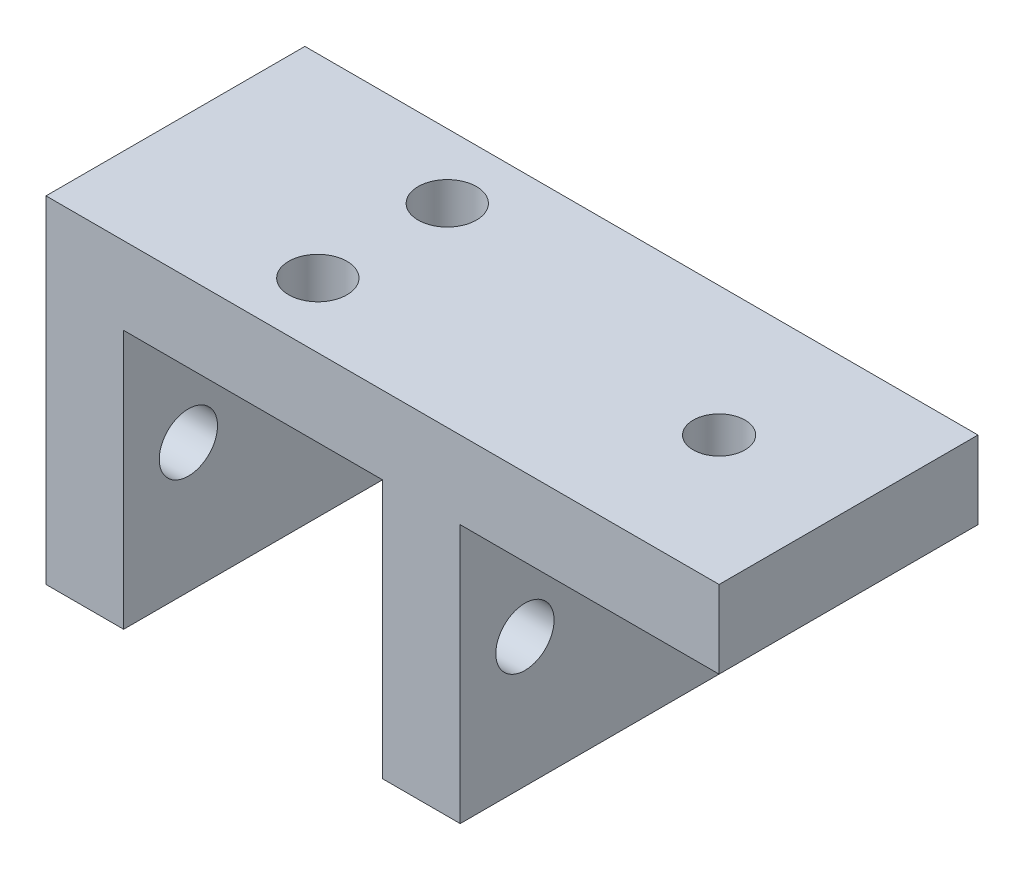
from build123d import *

# Parameters (mm, degrees)
BOSS_EXTRUDE3_DEPTH     = 20
SKETCH9_R               = 2.25
CUT_EXTRUDE1_DEPTH      = 47
CUT_EXTRUDE1_DEPTH_BACK = 7
SKETCH10_R              = 2.25
CUT_EXTRUDE2_DEPTH      = 21
CUT_EXTRUDE2_DEPTH_BACK = 7
SKETCH11_R              = 2
CUT_EXTRUDE3_DEPTH      = 21
CUT_EXTRUDE3_DEPTH_BACK = 7


with BuildPart() as part:
    # Sketch7 → Boss-Extrude3 (new body)
    with BuildSketch(Plane.XY):
        Polygon((-52, -26), (-52, 0), (0, 0), (0, -6), (-20, -6), (-20, -26), (-26, -26), (-26, -6), (-46, -6), (-46, -26), align=None)
    extrude(amount=BOSS_EXTRUDE3_DEPTH)

    # Sketch9 → Cut-Extrude1 (cut, two sides)
    with BuildSketch(Plane(origin=(-46, 0, 0), x_dir=(0, 0, -1), z_dir=(1, 0, 0))) as cut_extrude1_sk:
        with Locations((-15, -16)):
            Circle(SKETCH9_R)
        with Locations((-5, -16)):
            Circle(SKETCH9_R)
    extrude(amount=CUT_EXTRUDE1_DEPTH, mode=Mode.SUBTRACT)
    extrude(cut_extrude1_sk.sketch, amount=-CUT_EXTRUDE1_DEPTH_BACK, mode=Mode.SUBTRACT)

    # Sketch10 → Cut-Extrude2 (cut, two sides)
    with BuildSketch(Plane.XZ.offset(6)) as cut_extrude2_sk:
        with Locations((-36, 5)):
            Circle(SKETCH10_R)
        with Locations((-36, 15)):
            Circle(SKETCH10_R)
    extrude(amount=CUT_EXTRUDE2_DEPTH, mode=Mode.SUBTRACT)
    extrude(cut_extrude2_sk.sketch, amount=-CUT_EXTRUDE2_DEPTH_BACK, mode=Mode.SUBTRACT)

    # Sketch11 → Cut-Extrude3 (cut, two sides)
    with BuildSketch(Plane.XZ.offset(6)) as cut_extrude3_sk:
        with Locations((-10, 10)):
            Circle(SKETCH11_R)
    extrude(amount=CUT_EXTRUDE3_DEPTH, mode=Mode.SUBTRACT)
    extrude(cut_extrude3_sk.sketch, amount=-CUT_EXTRUDE3_DEPTH_BACK, mode=Mode.SUBTRACT)


solid = part.part
